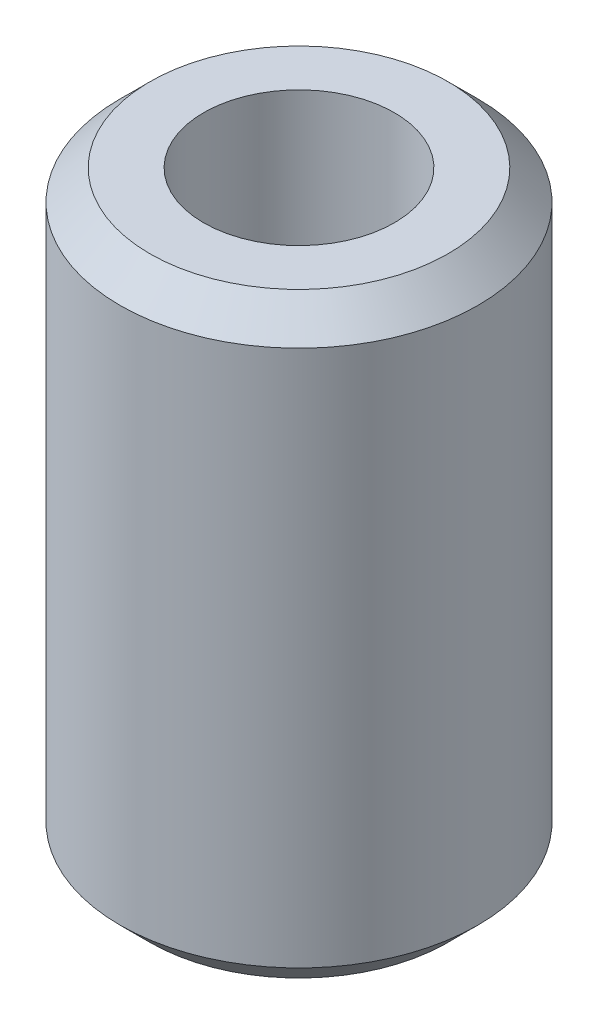
from build123d import *

# Parameters (mm, degrees)
SKETCH1_R           = 3
BOSS_EXTRUDE1_DEPTH = 10
SKETCH2_R           = 1.6
CUT_EXTRUDE1_DEPTH  = 10
CHAMFER1_SIZE       = 0.5


with BuildPart() as part:
    # Sketch1 → Boss-Extrude1 (new body)
    with BuildSketch(Plane(origin=(0, 0, 0), x_dir=(1, 0, 0), z_dir=(0, 1, 0))):
        Circle(SKETCH1_R)
    extrude(amount=BOSS_EXTRUDE1_DEPTH)

    # Sketch2 → Cut-Extrude1 (cut)
    with BuildSketch(Plane(origin=(0, 10, 0), x_dir=(1, 0, 0), z_dir=(0, 1, 0))):
        Circle(SKETCH2_R)
    extrude(amount=-CUT_EXTRUDE1_DEPTH, mode=Mode.SUBTRACT)

    # Chamfer1
    chamfer1_edges = [part.edges().sort_by_distance(p)[0] for p in [
        (-3, 0, 0),
        (-3, 10, 0),
    ]]
    chamfer(chamfer1_edges, length=CHAMFER1_SIZE)


solid = part.part
